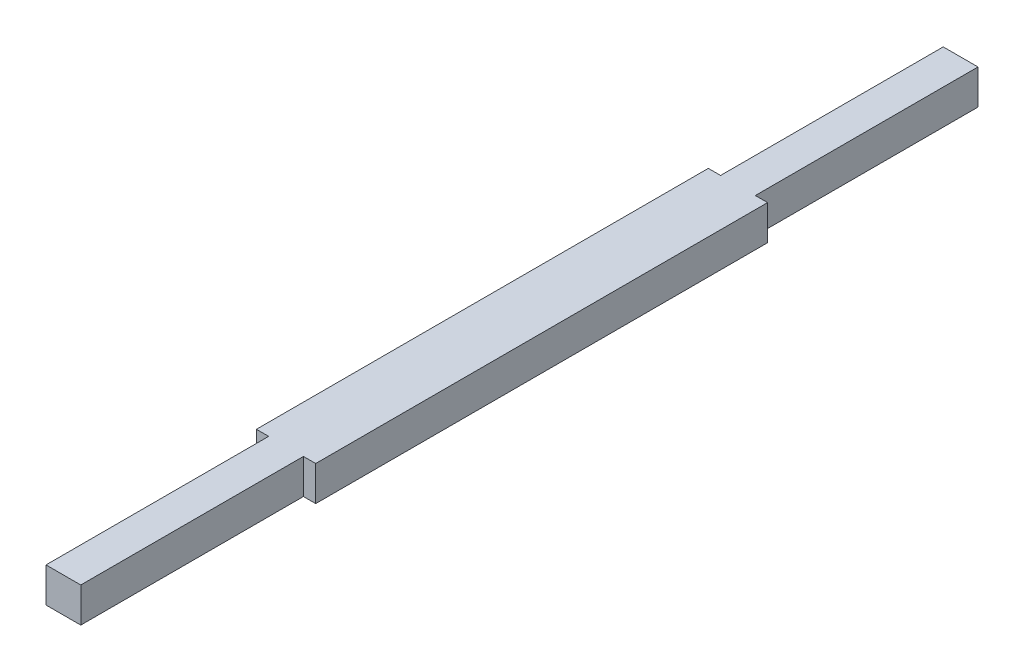
from build123d import *

# Parameters (mm, degrees)
SKETCH1_W           = 9
SKETCH1_H           = 9
BOSS_EXTRUDE1_DEPTH = 116.15
SKETCH2_W           = 3.175
SKETCH2_H           = 117
BOSS_EXTRUDE2_DEPTH = 4.5


with BuildPart() as part:
    # Sketch1 → Boss-Extrude1 (new body, symmetric)
    with BuildSketch(Plane.XY):
        Rectangle(SKETCH1_W, SKETCH1_H)
    extrude(amount=BOSS_EXTRUDE1_DEPTH, both=True)

    # Sketch2 → Boss-Extrude2 (add, symmetric)
    with BuildSketch(Plane(origin=(0, 0, 0), x_dir=(1, 0, 0), z_dir=(0, 1, 0))):
        with Locations((6.0875, 0)):
            Rectangle(SKETCH2_W, SKETCH2_H)
        with Locations((-6.0875, 0)):
            Rectangle(SKETCH2_W, SKETCH2_H)
    extrude(amount=BOSS_EXTRUDE2_DEPTH, both=True)


solid = part.part
